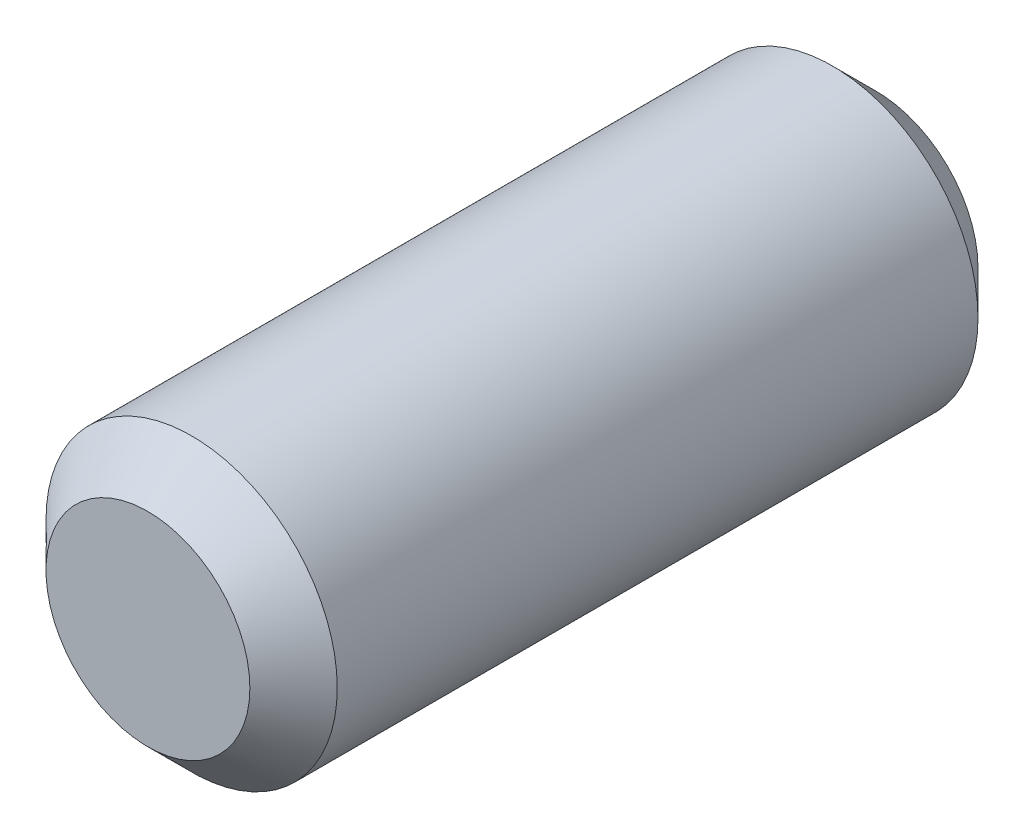
from build123d import *

# Parameters (mm, degrees)
SKETCH1_R           = 1
BOSS_EXTRUDE1_DEPTH = 5
CHAMFER1_SIZE       = 0.3


with BuildPart() as part:
    # Sketch1 → Boss-Extrude1 (new body)
    with BuildSketch(Plane.XY):
        Circle(SKETCH1_R)
    extrude(amount=BOSS_EXTRUDE1_DEPTH)

    # Chamfer1
    chamfer1_edges = [part.edges().sort_by_distance(p)[0] for p in [
        (-1, 0, 0),
        (-1, 0, 5),
    ]]
    chamfer(chamfer1_edges, length=CHAMFER1_SIZE)


solid = part.part
